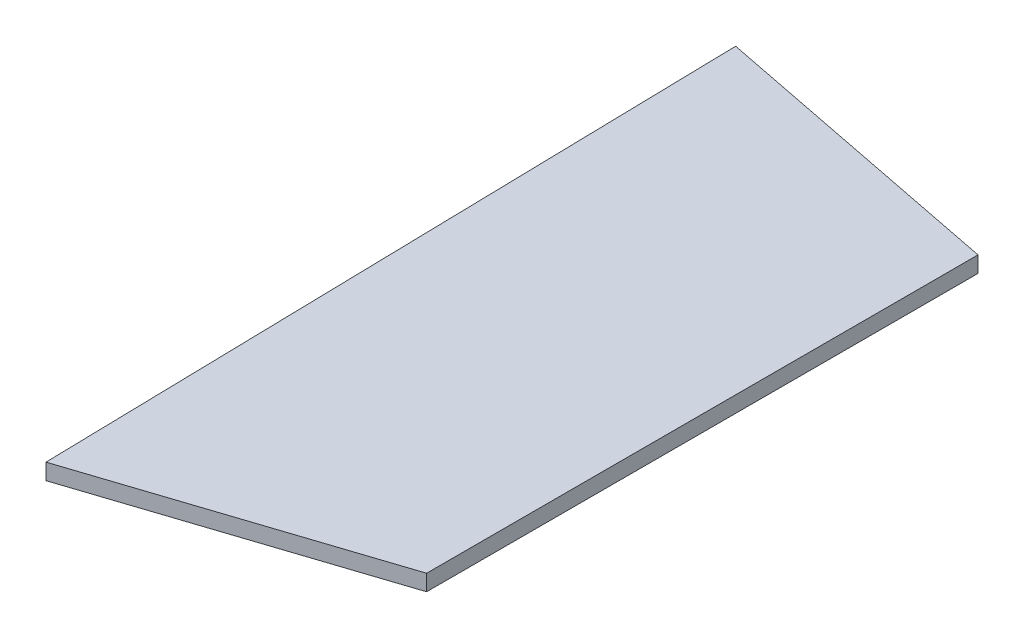
from build123d import *

# Parameters (mm, degrees)
BOSS_EXTRU_1_DEPTH = 2


with BuildPart() as part:
    # Esquisse1 → Boss.-Extru.1 (new body)
    with BuildSketch(Plane(origin=(0, 0, 0), x_dir=(1, 0, 0), z_dir=(0, 1, 0))):
        Polygon((35.648883612, 80.307693568), (-1.912055936, 87.716143523), (-1.854935649, 85.095733084), (0, 0), (35.648883612, 11.705769394), align=None)
    extrude(amount=BOSS_EXTRU_1_DEPTH)


solid = part.part
